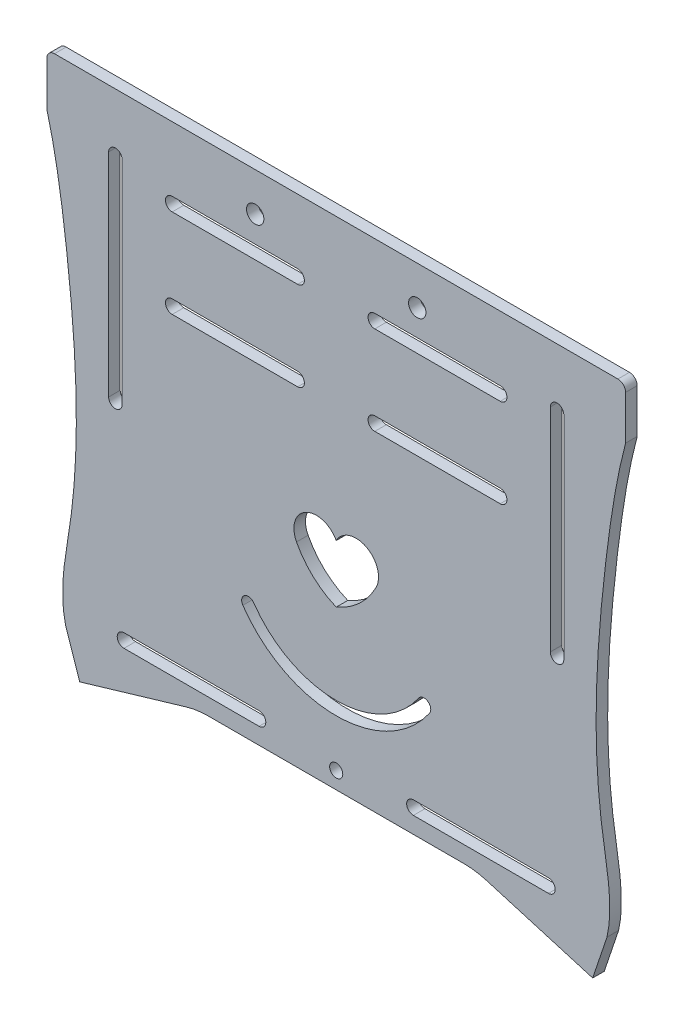
from build123d import *

# Parameters (mm, degrees)
EXTRUDE_1_DEPTH      = 3
SKETCH_7_R           = 1.75
SKETCH_7_R_2         = 2.25
CUT_EXTRUDE_2_DEPTH  = 143.955430949
CUT_EXTRUDE_4_DEPTH  = 3
CUT_EXTRUDE_5_DEPTH  = 3
CUT_EXTRUDE_8_DEPTH  = 3
SKETCH_12_R          = 1.7
CUT_EXTRUDE_9_DEPTH  = 3
SKETCH_13_R          = 1.7
CUT_EXTRUDE_11_DEPTH = 3
CUT_EXTRUDE_12_DEPTH = 143.955430949
FILLET_1_R           = 2
FILLET_2_R           = 2
CUT_EXTRUDE_13_DEPTH = 143.955430949
CUT_EXTRUDE_15_DEPTH = 143.955430949
CUT_EXTRUDE_16_DEPTH = 143.955430949
SKETCH_20_W          = 133.80338819
SKETCH_20_H          = 42.989432067
EXTRUDE_2_DEPTH      = 3
SKETCH_21_W          = 129.207272524
SKETCH_21_H          = 38.788932745
EXTRUDE_3_DEPTH      = 3
SKETCH_22_W          = 20.868569364
SKETCH_22_H          = 31.210515244
SKETCH_22_W_2        = 21.053246969
SKETCH_22_H_2        = 30.102449614
EXTRUDE_4_DEPTH      = 3
SKETCH_24_W          = 36.300662223
SKETCH_24_H          = 5.953308604
SKETCH_24_W_2        = 36.591067521
EXTRUDE_5_DEPTH      = 3
CUT_EXTRUDE_17_DEPTH = 143.955430949
CUT_EXTRUDE_19_DEPTH = 143.955430949
CUT_EXTRUDE_20_DEPTH = 143.955430949
CUT_EXTRUDE_21_DEPTH = 143.955430949
CUT_EXTRUDE_22_DEPTH = 143.955430949
CUT_EXTRUDE_23_DEPTH = 3
SKETCH_30_W          = 197.327919909
SKETCH_30_H          = 109.793735926
CUT_EXTRUDE_24_DEPTH = 10


with BuildPart() as part:
    # 草图1 → 凸台-拉伸1 (new body)
    with BuildSketch(Plane.XY):
        with BuildLine():
            Line((60, 106.603296002), (35.889163634, 121.664519159))
            Line((35.889163634, 121.664519159), (-35.889163634, 121.664519159))
            Line((-35.889163634, 121.664519159), (-60, 106.603296002))
            Line((-60, 106.603296002), (-60, 94.801892265))
            Line((-60, 94.801892265), (-45, 94.801892265))
            ThreePointArc((-45, 94.801892265), (-43.762563133, 94.289329132), (-43.25, 93.051892265))
            Line((-43.25, 93.051892265), (-37.75, 93.051892265))
            ThreePointArc((-37.75, 93.051892265), (-37.237436867, 94.289329132), (-36, 94.801892265))
            Line((-36, 94.801892265), (-21, 94.801892265))
            ThreePointArc((-21, 94.801892265), (-19.762563133, 94.289329132), (-19.25, 93.051892265))
            Line((-19.25, 93.051892265), (19.25, 93.051892265))
            ThreePointArc((19.25, 93.051892265), (19.762563133, 94.289329132), (21, 94.801892265))
            Line((21, 94.801892265), (36, 94.801892265))
            ThreePointArc((36, 94.801892265), (37.237436867, 94.289329132), (37.75, 93.051892265))
            Line((37.75, 93.051892265), (43.25, 93.051892265))
            ThreePointArc((43.25, 93.051892265), (43.762563133, 94.289329132), (45, 94.801892265))
            Line((45, 94.801892265), (60, 94.801892265))
            Line((60, 94.801892265), (60, 106.603296002))
        make_face()
        with BuildLine():
            Line((66.901694095, 102.292041372), (60, 106.603296002))
            Line((60, 106.603296002), (60, 94.801892265))
            ThreePointArc((60, 94.801892265), (61.237436867, 94.289329132), (61.75, 93.051892265))
            Line((61.75, 93.051892265), (66.901694095, 93.051892265))
            Line((66.901694095, 93.051892265), (66.901694095, 102.292041372))
        make_face()
        with BuildLine():
            Line((-60, 94.801892265), (-60, 106.603296002))
            Line((-60, 106.603296002), (-66.901694095, 102.292041372))
            Line((-66.901694095, 102.292041372), (-66.901694095, 93.051892265))
            Line((-66.901694095, 93.051892265), (-61.75, 93.051892265))
            ThreePointArc((-61.75, 93.051892265), (-61.237436867, 94.289329132), (-60, 94.801892265))
        make_face()
        with BuildLine():
            Line((66.901694095, 63.051892265), (66.901694095, 93.051892265))
            Line((66.901694095, 93.051892265), (61.75, 93.051892265))
            ThreePointArc((61.75, 93.051892265), (61.237436867, 91.814455398), (60, 91.301892265))
            Line((60, 91.301892265), (60, 64.801892265))
            ThreePointArc((60, 64.801892265), (61.237436867, 64.289329132), (61.75, 63.051892265))
            Line((61.75, 63.051892265), (66.901694095, 63.051892265))
        make_face()
        with BuildLine():
            Line((-61.75, 93.051892265), (-66.901694095, 93.051892265))
            Line((-66.901694095, 93.051892265), (-66.901694095, 63.051892265))
            Line((-66.901694095, 63.051892265), (-61.75, 63.051892265))
            ThreePointArc((-61.75, 63.051892265), (-61.237436867, 64.289329132), (-60, 64.801892265))
            Line((-60, 64.801892265), (-60, 91.301892265))
            ThreePointArc((-60, 91.301892265), (-61.237436867, 91.814455398), (-61.75, 93.051892265))
        make_face()
        with BuildLine():
            Line((66.901694095, 52.870133869), (66.901694095, 63.051892265))
            Line((66.901694095, 63.051892265), (61.75, 63.051892265))
            ThreePointArc((61.75, 63.051892265), (61.237436867, 61.814455398), (60, 61.301892265))
            Line((60, 61.301892265), (60, 31.261343001))
            Line((60, 31.261343001), (75, 31.261343001))
            Line((75, 31.261343001), (75, 40.933889795))
            ThreePointArc((75, 40.933889795), (69.117351927, 45.658052319), (66.901694095, 52.870133869))
        make_face()
        with BuildLine():
            Line((60, 64.801892265), (60, 91.301892265))
            Line((60, 91.301892265), (45, 91.301892265))
            ThreePointArc((45, 91.301892265), (43.762563133, 91.814455398), (43.25, 93.051892265))
            Line((43.25, 93.051892265), (37.75, 93.051892265))
            ThreePointArc((37.75, 93.051892265), (37.237436867, 91.814455398), (36, 91.301892265))
            Line((36, 91.301892265), (21, 91.301892265))
            ThreePointArc((21, 91.301892265), (19.762563133, 91.814455398), (19.25, 93.051892265))
            Line((19.25, 93.051892265), (-19.25, 93.051892265))
            ThreePointArc((-19.25, 93.051892265), (-19.762563133, 91.814455398), (-21, 91.301892265))
            Line((-21, 91.301892265), (-36, 91.301892265))
            ThreePointArc((-36, 91.301892265), (-37.237436867, 91.814455398), (-37.75, 93.051892265))
            Line((-37.75, 93.051892265), (-43.25, 93.051892265))
            ThreePointArc((-43.25, 93.051892265), (-43.762563133, 91.814455398), (-45, 91.301892265))
            Line((-45, 91.301892265), (-60, 91.301892265))
            Line((-60, 91.301892265), (-60, 64.801892265))
            Line((-60, 64.801892265), (-45, 64.801892265))
            ThreePointArc((-45, 64.801892265), (-43.762563133, 64.289329132), (-43.25, 63.051892265))
            Line((-43.25, 63.051892265), (-37.75, 63.051892265))
            ThreePointArc((-37.75, 63.051892265), (-37.237436867, 64.289329132), (-36, 64.801892265))
            Line((-36, 64.801892265), (-21, 64.801892265))
            ThreePointArc((-21, 64.801892265), (-19.762563133, 64.289329132), (-19.25, 63.051892265))
            Line((-19.25, 63.051892265), (19.25, 63.051892265))
            ThreePointArc((19.25, 63.051892265), (19.762563133, 64.289329132), (21, 64.801892265))
            Line((21, 64.801892265), (36, 64.801892265))
            ThreePointArc((36, 64.801892265), (37.237436867, 64.289329132), (37.75, 63.051892265))
            Line((37.75, 63.051892265), (43.25, 63.051892265))
            ThreePointArc((43.25, 63.051892265), (43.762563133, 64.289329132), (45, 64.801892265))
            Line((45, 64.801892265), (60, 64.801892265))
        make_face()
        with BuildLine():
            Line((-61.75, 63.051892265), (-66.901694095, 63.051892265))
            Line((-66.901694095, 63.051892265), (-66.901694095, 52.870133869))
            ThreePointArc((-66.901694095, 52.870133869), (-69.117351927, 45.658052319), (-75, 40.933889795))
            Line((-75, 40.933889795), (-75, 31.261343001))
            Line((-75, 31.261343001), (-60, 31.261343001))
            Line((-60, 31.261343001), (-60, 61.301892265))
            ThreePointArc((-60, 61.301892265), (-61.237436867, 61.814455398), (-61.75, 63.051892265))
        make_face()
        with BuildLine():
            Line((60, 31.261343001), (60, 61.301892265))
            Line((60, 61.301892265), (45, 61.301892265))
            ThreePointArc((45, 61.301892265), (43.762563133, 61.814455398), (43.25, 63.051892265))
            Line((43.25, 63.051892265), (37.75, 63.051892265))
            ThreePointArc((37.75, 63.051892265), (37.237436867, 61.814455398), (36, 61.301892265))
            Line((36, 61.301892265), (21, 61.301892265))
            ThreePointArc((21, 61.301892265), (19.762563133, 61.814455398), (19.25, 63.051892265))
            Line((19.25, 63.051892265), (-19.25, 63.051892265))
            ThreePointArc((-19.25, 63.051892265), (-19.762563133, 61.814455398), (-21, 61.301892265))
            Line((-21, 61.301892265), (-36, 61.301892265))
            ThreePointArc((-36, 61.301892265), (-37.237436867, 61.814455398), (-37.75, 63.051892265))
            Line((-37.75, 63.051892265), (-43.25, 63.051892265))
            ThreePointArc((-43.25, 63.051892265), (-43.762563133, 61.814455398), (-45, 61.301892265))
            Line((-45, 61.301892265), (-60, 61.301892265))
            Line((-60, 61.301892265), (-60, 31.261343001))
            Line((-60, 31.261343001), (60, 31.261343001))
        make_face()
        with BuildLine():
            Line((60, -58.312864289), (60, 23.940028391))
            Line((60, 23.940028391), (-60, 23.940028391))
            Line((-60, 23.940028391), (-60, -58.312864289))
            Line((-60, -58.312864289), (-45, -58.312864289))
            ThreePointArc((-45, -58.312864289), (-43.25, -60.062864289), (-45, -61.812864289))
            Line((-45, -61.812864289), (-60, -61.812864289))
            Line((-60, -61.812864289), (-60, -88.312864289))
            Line((-60, -88.312864289), (-45, -88.312864289))
            ThreePointArc((-45, -88.312864289), (-43.25, -90.062864289), (-45, -91.812864289))
            Line((-45, -91.812864289), (-60, -91.812864289))
            Line((-60, -91.812864289), (-60, -111.849967256))
            Line((-60, -111.849967256), (-38.845469114, -105.590576733))
            ThreePointArc((-38.845469114, -105.590576733), (-36.037784492, -104.975210108), (-33.17088573, -104.768665882))
            Line((-33.17088573, -104.768665882), (33.17088573, -104.768665882))
            ThreePointArc((33.17088573, -104.768665882), (36.037784492, -104.975210108), (38.845469114, -105.590576733))
            Line((38.845469114, -105.590576733), (60, -111.849967256))
            Line((60, -111.849967256), (60, -91.812864289))
            Line((60, -91.812864289), (45, -91.812864289))
            ThreePointArc((45, -91.812864289), (43.762563133, -91.300301156), (43.25, -90.062864289))
            ThreePointArc((43.25, -90.062864289), (43.762563133, -88.825427422), (45, -88.312864289))
            Line((45, -88.312864289), (60, -88.312864289))
            Line((60, -88.312864289), (60, -61.812864289))
            Line((60, -61.812864289), (45, -61.812864289))
            ThreePointArc((45, -61.812864289), (43.762563133, -61.300301156), (43.25, -60.062864289))
            ThreePointArc((43.25, -60.062864289), (43.762563133, -58.825427422), (45, -58.312864289))
            Line((45, -58.312864289), (60, -58.312864289))
        make_face()
        with BuildLine():
            ThreePointArc((-21, -88.312864289), (-19.762563133, -88.825427422), (-19.25, -90.062864289))
            ThreePointArc((-19.25, -90.062864289), (-19.762563133, -91.300301156), (-21, -91.812864289))
            Line((-21, -91.812864289), (-36, -91.812864289))
            ThreePointArc((-36, -91.812864289), (-37.75, -90.062864289), (-36, -88.312864289))
            Line((-36, -88.312864289), (-21, -88.312864289))
        make_face(mode=Mode.SUBTRACT)
        with BuildLine():
            ThreePointArc((-21, -58.312864289), (-19.762563133, -58.825427422), (-19.25, -60.062864289))
            ThreePointArc((-19.25, -60.062864289), (-19.762563133, -61.300301156), (-21, -61.812864289))
            Line((-21, -61.812864289), (-36, -61.812864289))
            ThreePointArc((-36, -61.812864289), (-37.75, -60.062864289), (-36, -58.312864289))
            Line((-36, -58.312864289), (-21, -58.312864289))
        make_face(mode=Mode.SUBTRACT)
        with BuildLine():
            ThreePointArc((36, -88.312864289), (37.237436867, -88.825427422), (37.75, -90.062864289))
            ThreePointArc((37.75, -90.062864289), (37.237436867, -91.300301156), (36, -91.812864289))
            Line((36, -91.812864289), (21, -91.812864289))
            ThreePointArc((21, -91.812864289), (19.762563133, -91.300301156), (19.25, -90.062864289))
            ThreePointArc((19.25, -90.062864289), (19.762563133, -88.825427422), (21, -88.312864289))
            Line((21, -88.312864289), (36, -88.312864289))
        make_face(mode=Mode.SUBTRACT)
        with BuildLine():
            ThreePointArc((36, -58.312864289), (37.237436867, -58.825427422), (37.75, -60.062864289))
            ThreePointArc((37.75, -60.062864289), (37.237436867, -61.300301156), (36, -61.812864289))
            Line((36, -61.812864289), (21, -61.812864289))
            ThreePointArc((21, -61.812864289), (19.762563133, -61.300301156), (19.25, -60.062864289))
            ThreePointArc((19.25, -60.062864289), (19.762563133, -58.825427422), (21, -58.312864289))
            Line((21, -58.312864289), (36, -58.312864289))
        make_face(mode=Mode.SUBTRACT)
        with BuildLine():
            Line((75, 23.940028391), (60, 23.940028391))
            Line((60, 23.940028391), (60, -58.312864289))
            ThreePointArc((60, -58.312864289), (61.237436867, -58.825427422), (61.75, -60.062864289))
            Line((61.75, -60.062864289), (67.402721334, -60.062864289))
            add(Edge.make_bspline(
                [(75, 10.562559835), (72.695878257, 1.907314233), (70.339582535, -13.372796253), (67.818206704, -36.939032951), (67.208860388, -51.77269444), (67.402721334, -60.062864289)],
                knots=[0, 0, 0, 0, 0.235246678, 0.40629419, 0.624108181, 0.624108181, 0.624108181, 0.624108181], degree=3))
            Line((75, 10.562559835), (75, 23.940028391))
        make_face()
        with BuildLine():
            Line((-60, -58.312864289), (-60, 23.940028391))
            Line((-60, 23.940028391), (-75, 23.940028391))
            Line((-75, 23.940028391), (-75, 10.562559835))
            add(Edge.make_bspline(
                [(-75, 10.562559835), (-72.695878257, 1.907314233), (-70.339582535, -13.372796253), (-67.818206704, -36.939032951), (-67.208860388, -51.77269444), (-67.402721334, -60.062864289)],
                knots=[0, 0, 0, 0, 0.235246678, 0.40629419, 0.624108181, 0.624108181, 0.624108181, 0.624108181], degree=3))
            add(Edge.make_bspline(
                [(-67.402721334, -60.062864289), (-67.560325872, -66.802583754), (-68.323504015, -76.843670093), (-70.154131955, -86.778530076), (-70.533712858, -90.062864289)],
                knots=[0.624108181, 0.624108181, 0.624108181, 0.624108181, 0.801186001, 0.888408652, 0.888408652, 0.888408652, 0.888408652], degree=3))
            add(Edge.make_bspline(
                [(-70.533712858, -90.062864289), (-71.019342956, -94.264792095), (-71.137422935, -98.476048206), (-70.1742624, -102.732794059)],
                knots=[0.888408652, 0.888408652, 0.888408652, 0.888408652, 1, 1, 1, 1], degree=3))
            Line((-70.1742624, -102.732794059), (-66.460817635, -113.761651372))
            Line((-66.460817635, -113.761651372), (-60, -111.849967256))
            Line((-60, -111.849967256), (-60, -91.812864289))
            ThreePointArc((-60, -91.812864289), (-61.75, -90.062864289), (-60, -88.312864289))
            Line((-60, -88.312864289), (-60, -61.812864289))
            ThreePointArc((-60, -61.812864289), (-61.75, -60.062864289), (-60, -58.312864289))
        make_face()
        with BuildLine():
            Line((67.402721334, -60.062864289), (61.75, -60.062864289))
            ThreePointArc((61.75, -60.062864289), (61.237436867, -61.300301156), (60, -61.812864289))
            Line((60, -61.812864289), (60, -88.312864289))
            ThreePointArc((60, -88.312864289), (61.237436867, -88.825427422), (61.75, -90.062864289))
            Line((61.75, -90.062864289), (70.533712858, -90.062864289))
            add(Edge.make_bspline(
                [(67.402721334, -60.062864289), (67.560325872, -66.802583754), (68.323504015, -76.843670093), (70.154131955, -86.778530076), (70.533712858, -90.062864289)],
                knots=[0.624108181, 0.624108181, 0.624108181, 0.624108181, 0.801186001, 0.888408652, 0.888408652, 0.888408652, 0.888408652], degree=3))
        make_face()
        with BuildLine():
            add(Edge.make_bspline(
                [(70.533712858, -90.062864289), (71.019342956, -94.264792095), (71.137422935, -98.476048206), (70.1742624, -102.732794059)],
                knots=[0.888408652, 0.888408652, 0.888408652, 0.888408652, 1, 1, 1, 1], degree=3))
            Line((70.533712858, -90.062864289), (61.75, -90.062864289))
            ThreePointArc((61.75, -90.062864289), (61.237436867, -91.300301156), (60, -91.812864289))
            Line((60, -91.812864289), (60, -111.849967256))
            Line((60, -111.849967256), (66.460817635, -113.761651372))
            Line((66.460817635, -113.761651372), (70.1742624, -102.732794059))
        make_face()
    extrude(amount=EXTRUDE_1_DEPTH)

    # 草图7 → 切除-拉伸2 (cut, through all)
    with BuildSketch(Plane(origin=(0, 0, 0), x_dir=(-1, 0, 0), z_dir=(0, 0, -1))):
        with Locations((-21, 41.261343001)):
            Circle(SKETCH_7_R)
        with Locations((21, 41.261343001)):
            Circle(SKETCH_7_R)
        with Locations((-21, 13.940028391)):
            Circle(SKETCH_7_R_2)
        with Locations((21, 13.940028391)):
            Circle(SKETCH_7_R_2)
    extrude(amount=-CUT_EXTRUDE_2_DEPTH, mode=Mode.SUBTRACT)

    # 草图9 → 切除-拉伸4 (cut)
    with BuildSketch(Plane.XY.offset(3)):
        with BuildLine():
            Line((55, -100.49704609), (20, -100.49704609))
            ThreePointArc((20, -100.49704609), (18.25, -98.74704609), (20, -96.99704609))
            Line((20, -96.99704609), (55, -96.99704609))
            ThreePointArc((55, -96.99704609), (56.75, -98.74704609), (55, -100.49704609))
        make_face()
        with BuildLine():
            Line((-55, -96.99704609), (-20, -96.99704609))
            ThreePointArc((-20, -96.99704609), (-18.25, -98.74704609), (-20, -100.49704609))
            Line((-20, -100.49704609), (-55, -100.49704609))
            ThreePointArc((-55, -100.49704609), (-56.75, -98.74704609), (-55, -96.99704609))
        make_face()
    extrude(amount=-CUT_EXTRUDE_4_DEPTH, mode=Mode.SUBTRACT)

    # 草图10 → 切除-拉伸5 (cut)
    with BuildSketch(Plane.XY.offset(3)):
        with BuildLine():
            Line((12.5, -80.062864289), (-12.5, -80.062864289))
            ThreePointArc((-12.5, -80.062864289), (-17.5, -75.062864289), (-12.5, -70.062864289))
            Line((-12.5, -70.062864289), (12.5, -70.062864289))
            ThreePointArc((12.5, -70.062864289), (17.5, -75.062864289), (12.5, -80.062864289))
        make_face()
    extrude(amount=-CUT_EXTRUDE_5_DEPTH, mode=Mode.SUBTRACT)

    # 草图11 → 切除-拉伸8 (cut)
    with BuildSketch(Plane.XY.offset(3)):
        with BuildLine():
            Line((15, 73.051892265), (-15, 73.051892265))
            ThreePointArc((-15, 73.051892265), (-20, 78.051892265), (-15, 83.051892265))
            Line((-15, 83.051892265), (15, 83.051892265))
            ThreePointArc((15, 83.051892265), (20, 78.051892265), (15, 73.051892265))
        make_face()
    extrude(amount=-CUT_EXTRUDE_8_DEPTH, mode=Mode.SUBTRACT)

    # 草图12 → 切除-拉伸9 (cut)
    with BuildSketch(Plane.XY.offset(3)):
        with Locations((0, 114.371786435)):
            Circle(SKETCH_12_R)
        with Locations((0, 98.371786435)):
            Circle(SKETCH_12_R)
        with Locations((8, 106.371786435)):
            Circle(SKETCH_12_R)
        with Locations((-8, 106.371786435)):
            Circle(SKETCH_12_R)
    extrude(amount=-CUT_EXTRUDE_9_DEPTH, mode=Mode.SUBTRACT)

    # 草图13 → 切除-拉伸11 (cut)
    with BuildSketch(Plane.XY.offset(3)):
        with Locations((0, -84.415765086)):
            Circle(SKETCH_13_R)
        with Locations((8, -92.415765086)):
            Circle(SKETCH_13_R)
        with Locations((0, -100.415765086)):
            Circle(SKETCH_13_R)
        with Locations((-8, -92.415765086)):
            Circle(SKETCH_13_R)
    extrude(amount=-CUT_EXTRUDE_11_DEPTH, mode=Mode.SUBTRACT)

    # 草图14 → 切除-拉伸12 (cut, through all)
    with BuildSketch(Plane.XY.offset(3)):
        with BuildLine():
            Line((-55.475501567, 8.919687236), (-55.475501567, -46.080312764))
            ThreePointArc((-55.475501567, -46.080312764), (-57.225501567, -47.830312764), (-58.975501567, -46.080312764))
            Line((-58.975501567, -46.080312764), (-58.975501567, 8.919687236))
            ThreePointArc((-58.975501567, 8.919687236), (-57.225501567, 10.669687236), (-55.475501567, 8.919687236))
        make_face()
        with BuildLine():
            Line((58.975501567, 8.919687236), (58.975501567, -46.080312764))
            ThreePointArc((58.975501567, -46.080312764), (57.225501567, -47.830312764), (55.475501567, -46.080312764))
            Line((55.475501567, -46.080312764), (55.475501567, 8.919687236))
            ThreePointArc((55.475501567, 8.919687236), (57.225501567, 10.669687236), (58.975501567, 8.919687236))
        make_face()
    extrude(amount=-CUT_EXTRUDE_12_DEPTH, mode=Mode.SUBTRACT)

    # 圆角1
    fillet_1_edges = [part.edges().sort_by_distance(p)[0] for p in [
        (75, 31.261343001, 1.5),
        (-75, 31.261343001, 1.5),
    ]]
    fillet(fillet_1_edges, radius=FILLET_1_R)

    # 圆角2
    fillet_2_edges = [part.edges().sort_by_distance(p)[0] for p in [
        (-75, 23.940028391, 1.5),
        (75, 23.940028391, 1.5),
    ]]
    fillet(fillet_2_edges, radius=FILLET_2_R)

    # 草图15 → 切除-拉伸13 (cut, through all)
    with BuildSketch(Plane(origin=(0, 0, 0), x_dir=(-1, 0, 0), z_dir=(0, 0, -1))):
        with BuildLine():
            Line((-61.184216401, 102.403501276), (-34.774762862, 118.900592756))
            ThreePointArc((-34.774762862, 118.900592756), (-32.70788159, 118.423097411), (-33.185376934, 116.356216138))
            Line((-33.185376934, 116.356216138), (-59.594830473, 99.859124658))
            ThreePointArc((-59.594830473, 99.859124658), (-61.661711746, 100.336620003), (-61.184216401, 102.403501276))
        make_face()
        with BuildLine():
            Line((59.594830473, 99.859124658), (33.185376934, 116.356216138))
            ThreePointArc((33.185376934, 116.356216138), (32.70788159, 118.423097411), (34.774762862, 118.900592756))
            Line((34.774762862, 118.900592756), (61.184216401, 102.403501276))
            ThreePointArc((61.184216401, 102.403501276), (61.661711746, 100.336620003), (59.594830473, 99.859124658))
        make_face()
    extrude(amount=-CUT_EXTRUDE_13_DEPTH, mode=Mode.SUBTRACT)

    # 草图17 → 切除-拉伸15 (cut, through all)
    with BuildSketch(Plane(origin=(0, 0, 0), x_dir=(-1, 0, 0), z_dir=(0, 0, -1))):
        Polygon((-28.645414283, -8.118433382), (-34.644957411, -20.11751964), (-34.644957411, -29.946558382), (-37.580904049, -29.946558382), (-37.580904049, -20.11751964), (-43.580447177, -8.118433382), (-40.64450054, -8.118433382), (-36.176755657, -17.43687271), (-36.049105803, -17.43687271), (-31.58136092, -8.118433382), align=None)
    extrude(amount=-CUT_EXTRUDE_15_DEPTH, mode=Mode.SUBTRACT)

    # 草图18 → 切除-拉伸16 (cut, through all)
    with BuildSketch(Plane(origin=(0, 0, 0), x_dir=(-1, 0, 0), z_dir=(0, 0, -1))):
        Polygon((46.06697123, -29.087529791), (43.131024593, -29.087529791), (43.131024593, -18.875541487), (35.854982926, -18.875541487), (35.854982926, -29.087529791), (32.919036289, -29.087529791), (32.919036289, -7.259404791), (35.854982926, -7.259404791), (35.854982926, -16.450194265), (43.131024593, -16.450194265), (43.131024593, -7.259404791), (46.06697123, -7.259404791), align=None)
    extrude(amount=-CUT_EXTRUDE_16_DEPTH, mode=Mode.SUBTRACT)

    # 草图20 → 凸台-拉伸2 (add)
    with BuildSketch(Plane(origin=(0, 0, 0), x_dir=(-1, 0, 0), z_dir=(0, 0, -1))):
        with Locations((0, 74.364849902)):
            Rectangle(SKETCH_20_W, SKETCH_20_H)
    extrude(amount=-EXTRUDE_2_DEPTH)

    # 草图21 → 凸台-拉伸3 (add)
    with BuildSketch(Plane(origin=(0, 0, 0), x_dir=(-1, 0, 0), z_dir=(0, 0, -1))):
        with Locations((-0.162688936, -75.817262983)):
            Rectangle(SKETCH_21_W, SKETCH_21_H)
    extrude(amount=-EXTRUDE_3_DEPTH)

    # 草图22 → 凸台-拉伸4 (add)
    with BuildSketch(Plane(origin=(0, 0, 0), x_dir=(-1, 0, 0), z_dir=(0, 0, -1))):
        with Locations((-36.28455521, -18.718035035)):
            Rectangle(SKETCH_22_W, SKETCH_22_H)
        with Locations((39.340924035, -18.16400222)):
            Rectangle(SKETCH_22_W_2, SKETCH_22_H_2)
    extrude(amount=-EXTRUDE_4_DEPTH)

    # 草图24 → 凸台-拉伸5 (add)
    with BuildSketch(Plane(origin=(0, 0, 0), x_dir=(-1, 0, 0), z_dir=(0, 0, -1))):
        with Locations((-46.84572901, 41.350914957)):
            Rectangle(SKETCH_24_W, SKETCH_24_H)
        with Locations((47.53599277, 41.350914957)):
            Rectangle(SKETCH_24_W_2, SKETCH_24_H)
    extrude(amount=-EXTRUDE_5_DEPTH)

    # 草图25 → 切除-拉伸17 (cut, through all)
    with BuildSketch(Plane(origin=(0, 0, 0), x_dir=(-1, 0, 0), z_dir=(0, 0, -1))):
        with BuildLine():
            Line((-14.658238954, 113.011343001), (-32.658238954, 113.011343001))
            ThreePointArc((-32.658238954, 113.011343001), (-34.408238954, 111.261343001), (-32.658238954, 109.511343001))
            Line((-32.658238954, 109.511343001), (-14.658238954, 109.511343001))
            ThreePointArc((-14.658238954, 109.511343001), (-12.908238954, 111.261343001), (-14.658238954, 113.011343001))
        make_face()
        with BuildLine():
            Line((-20.999999982, 43.011343001), (-32.658238954, 43.011343001))
            ThreePointArc((-32.658238954, 43.011343001), (-34.408238954, 41.261343001), (-32.658238954, 39.511343001))
            Line((-32.658238954, 39.511343001), (-21, 39.511343001))
            ThreePointArc((-21, 39.511343001), (-22.75, 41.26134301), (-20.999999982, 43.011343001))
        make_face()
        with BuildLine():
            ThreePointArc((14.341761046, 113.011343001), (12.591761046, 111.261343001), (14.341761046, 109.511343001))
            Line((14.341761046, 109.511343001), (32.341761046, 109.511343001))
            ThreePointArc((32.341761046, 109.511343001), (34.091761046, 111.261343001), (32.341761046, 113.011343001))
            Line((32.341761046, 113.011343001), (14.341761046, 113.011343001))
        make_face()
        with BuildLine():
            Line((-14.658238954, 43.011343001), (-20.999999982, 43.011343001))
            ThreePointArc((-20.999999982, 43.011343001), (-19.25, 41.261342991), (-21, 39.511343001))
            Line((-21, 39.511343001), (-14.658238954, 39.511343001))
            ThreePointArc((-14.658238954, 39.511343001), (-12.908238954, 41.261343001), (-14.658238954, 43.011343001))
        make_face()
        with BuildLine():
            ThreePointArc((32.341761046, 39.511343001), (34.091761046, 41.261343001), (32.341761046, 43.011343001))
            Line((32.341761046, 43.011343001), (21, 43.011343001))
            ThreePointArc((21, 43.011343001), (22.75, 41.261343001), (21, 39.511343001))
            Line((21, 39.511343001), (32.341761046, 39.511343001))
        make_face()
        with BuildLine():
            ThreePointArc((14.341761046, 43.011343001), (12.591761046, 41.261343001), (14.341761046, 39.511343001))
            Line((14.341761046, 39.511343001), (21, 39.511343001))
            ThreePointArc((21, 39.511343001), (19.25, 41.261343001), (21, 43.011343001))
            Line((21, 43.011343001), (14.341761046, 43.011343001))
        make_face()
    extrude(amount=-CUT_EXTRUDE_17_DEPTH, mode=Mode.SUBTRACT)

    # 草图16 → 切除-拉伸19 (cut, through all)
    with BuildSketch(Plane(origin=(0, 0, 0), x_dir=(-1, 0, 0), z_dir=(0, 0, -1))):
        with BuildLine():
            Line((-62, 43.011343001), (-32, 43.011343001))
            ThreePointArc((-32, 43.011343001), (-30.25, 41.261343001), (-32, 39.511343001))
            Line((-32, 39.511343001), (-62, 39.511343001))
            ThreePointArc((-62, 39.511343001), (-63.75, 41.261343001), (-62, 43.011343001))
        make_face()
        with BuildLine():
            Line((62, 39.511343001), (32, 39.511343001))
            ThreePointArc((32, 39.511343001), (30.25, 41.261343001), (32, 43.011343001))
            Line((32, 43.011343001), (62, 43.011343001))
            ThreePointArc((62, 43.011343001), (63.75, 41.261343001), (62, 39.511343001))
        make_face()
    extrude(amount=-CUT_EXTRUDE_19_DEPTH, mode=Mode.SUBTRACT)

    # 草图26 → 切除-拉伸20 (cut, through all)
    with BuildSketch(Plane(origin=(0, 0, 0), x_dir=(-1, 0, 0), z_dir=(0, 0, -1))):
        with BuildLine():
            Line((15, 71.876956146), (-15, 71.876956146))
            ThreePointArc((-15, 71.876956146), (-20, 76.876956146), (-15, 81.876956146))
            Line((-15, 81.876956146), (15, 81.876956146))
            ThreePointArc((15, 81.876956146), (20, 76.876956146), (15, 71.876956146))
        make_face()
    extrude(amount=-CUT_EXTRUDE_20_DEPTH, mode=Mode.SUBTRACT)

    # 草图27 → 切除-拉伸21 (cut, through all)
    with BuildSketch(Plane(origin=(0, 0, 0), x_dir=(-1, 0, 0), z_dir=(0, 0, -1))):
        with BuildLine():
            Line((-10, -15.809971609), (-42.5, -15.809971609))
            ThreePointArc((-42.5, -15.809971609), (-44.25, -17.559971609), (-42.5, -19.309971609))
            Line((-42.5, -19.309971609), (-10, -19.309971609))
            ThreePointArc((-10, -19.309971609), (-8.25, -17.559971609), (-10, -15.809971609))
        make_face()
        with BuildLine():
            ThreePointArc((-42.5, 7.190028391), (-44.25, 5.440028391), (-42.5, 3.690028391))
            Line((-42.5, 3.690028391), (-10, 3.690028391))
            ThreePointArc((-10, 3.690028391), (-8.25, 5.440028391), (-10, 7.190028391))
            Line((-10, 7.190028391), (-42.5, 7.190028391))
        make_face()
        with BuildLine():
            Line((42.5, -15.809971609), (10, -15.809971609))
            ThreePointArc((10, -15.809971609), (8.25, -17.559971609), (10, -19.309971609))
            Line((10, -19.309971609), (42.5, -19.309971609))
            ThreePointArc((42.5, -19.309971609), (44.25, -17.559971609), (42.5, -15.809971609))
        make_face()
        with BuildLine():
            Line((42.5, 7.190028391), (10, 7.190028391))
            ThreePointArc((10, 7.190028391), (8.25, 5.440028391), (10, 3.690028391))
            Line((10, 3.690028391), (42.5, 3.690028391))
            ThreePointArc((42.5, 3.690028391), (44.25, 5.440028391), (42.5, 7.190028391))
        make_face()
    extrude(amount=-CUT_EXTRUDE_21_DEPTH, mode=Mode.SUBTRACT)

    # 草图28 → 切除-拉伸22 (cut, through all)
    with BuildSketch(Plane(origin=(0, 0, 0), x_dir=(-1, 0, 0), z_dir=(0, 0, -1))):
        with BuildLine():
            ThreePointArc((0, -48.812330529), (-7.86916468, -46.39674179), (-10.284753419, -54.26590647))
            ThreePointArc((-10.284753419, -54.26590647), (-5.977554294, -59.915955393), (0, -63.755729058))
            ThreePointArc((0, -63.755729058), (5.977554294, -59.915955393), (10.284753419, -54.26590647))
            ThreePointArc((10.284753419, -54.26590647), (7.86916468, -46.39674179), (0, -48.812330529))
        make_face()
    extrude(amount=-CUT_EXTRUDE_22_DEPTH, mode=Mode.SUBTRACT)

    # 草图29 → 切除-拉伸23 (cut)
    with BuildSketch(Plane(origin=(0, 0, 0), x_dir=(-1, 0, 0), z_dir=(0, 0, -1))):
        with BuildLine():
            ThreePointArc((-21.368709037, -73.490793052), (0, -84.713248851), (21.368709037, -73.490793052))
            ThreePointArc((21.368709037, -73.490793052), (23.760053677, -73.051240341), (24.199606389, -75.442584981))
            ThreePointArc((24.199606389, -75.442584981), (0, -88.151776376), (-24.199606389, -75.442584981))
            ThreePointArc((-24.199606389, -75.442584981), (-23.760053677, -73.051240341), (-21.368709037, -73.490793052))
        make_face()
    extrude(amount=-CUT_EXTRUDE_23_DEPTH, mode=Mode.SUBTRACT)

    # 草图30 → 切除-拉伸24 (cut)
    with BuildSketch(Plane(origin=(0, 0, 0), x_dir=(-1, 0, 0), z_dir=(0, 0, -1))):
        with Locations((-6.729627317, 80.456828536)):
            Rectangle(SKETCH_30_W, SKETCH_30_H)
    extrude(amount=-CUT_EXTRUDE_24_DEPTH, mode=Mode.SUBTRACT)


solid = part.part
